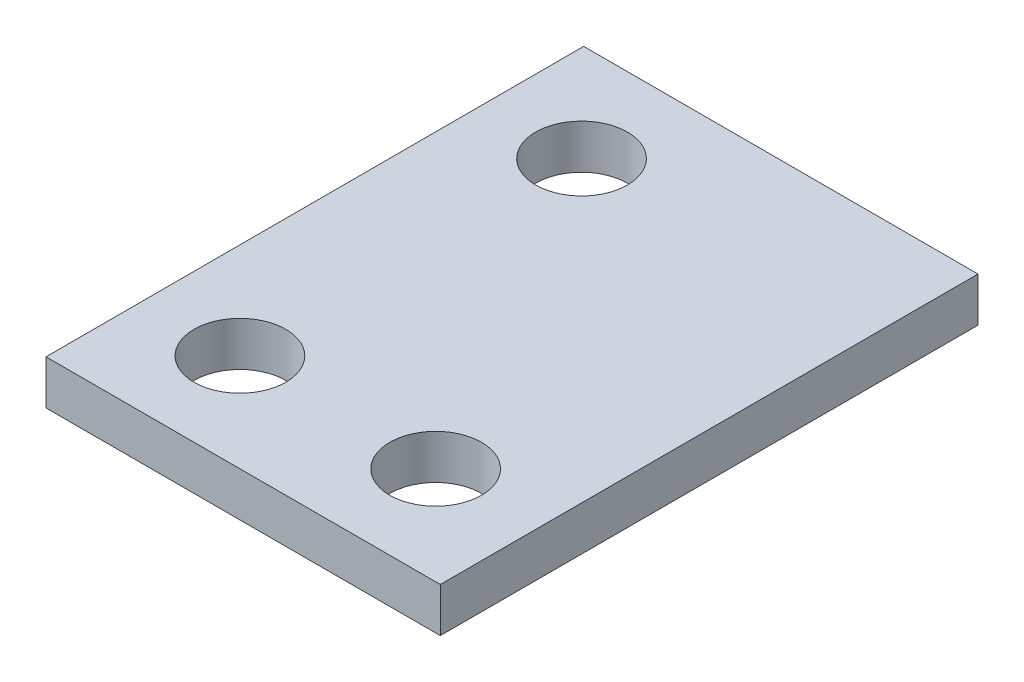
from build123d import *

# Parameters (mm, degrees)
SKETCH1_W           = 13.97
SKETCH1_H           = 19.05
BOSS_EXTRUDE1_DEPTH = 1.57
CUT_EXTRUDE1_REACH  = 3.57
SKETCH4_R           = 1.6256


with BuildPart() as part:
    # Sketch1 → Boss-Extrude1 (new body)
    with BuildSketch(Plane(origin=(0, 0, 0), x_dir=(1, 0, 0), z_dir=(0, 1, 0))):
        Rectangle(SKETCH1_W, SKETCH1_H)
    extrude(amount=BOSS_EXTRUDE1_DEPTH)

    # Sketch4 → Cut-Extrude1 (cut, up to next)
    with BuildSketch(Plane(origin=(0, 1.57, 0), x_dir=(1, 0, 0), z_dir=(0, 1, 0)), mode=Mode.PRIVATE) as cut_extrude1_sk1:
        with Locations((-3.5814, -6.0579)):
            Circle(SKETCH4_R)
    cut_extrude1_tool1 = extrude(cut_extrude1_sk1.sketch, amount=-CUT_EXTRUDE1_REACH, mode=Mode.PRIVATE) & part.part
    add(cut_extrude1_tool1.solids().sort_by_distance((-3.5814, 1.57, 6.0579))[0], mode=Mode.SUBTRACT)
    # Sketch4 → Cut-Extrude1 (cut, up to next)
    with BuildSketch(Plane(origin=(0, 1.57, 0), x_dir=(1, 0, 0), z_dir=(0, 1, 0)), mode=Mode.PRIVATE) as cut_extrude1_sk2:
        with Locations((3.3528, -6.0579)):
            Circle(SKETCH4_R)
    cut_extrude1_tool2 = extrude(cut_extrude1_sk2.sketch, amount=-CUT_EXTRUDE1_REACH, mode=Mode.PRIVATE) & part.part
    add(cut_extrude1_tool2.solids().sort_by_distance((3.3528, 1.57, 6.0579))[0], mode=Mode.SUBTRACT)
    # Sketch4 → Cut-Extrude1 (cut, up to next)
    with BuildSketch(Plane(origin=(0, 1.57, 0), x_dir=(1, 0, 0), z_dir=(0, 1, 0)), mode=Mode.PRIVATE) as cut_extrude1_sk3:
        with Locations((-3.5814, 6.0452)):
            Circle(SKETCH4_R)
    cut_extrude1_tool3 = extrude(cut_extrude1_sk3.sketch, amount=-CUT_EXTRUDE1_REACH, mode=Mode.PRIVATE) & part.part
    add(cut_extrude1_tool3.solids().sort_by_distance((-3.5814, 1.57, -6.0452))[0], mode=Mode.SUBTRACT)


solid = part.part
